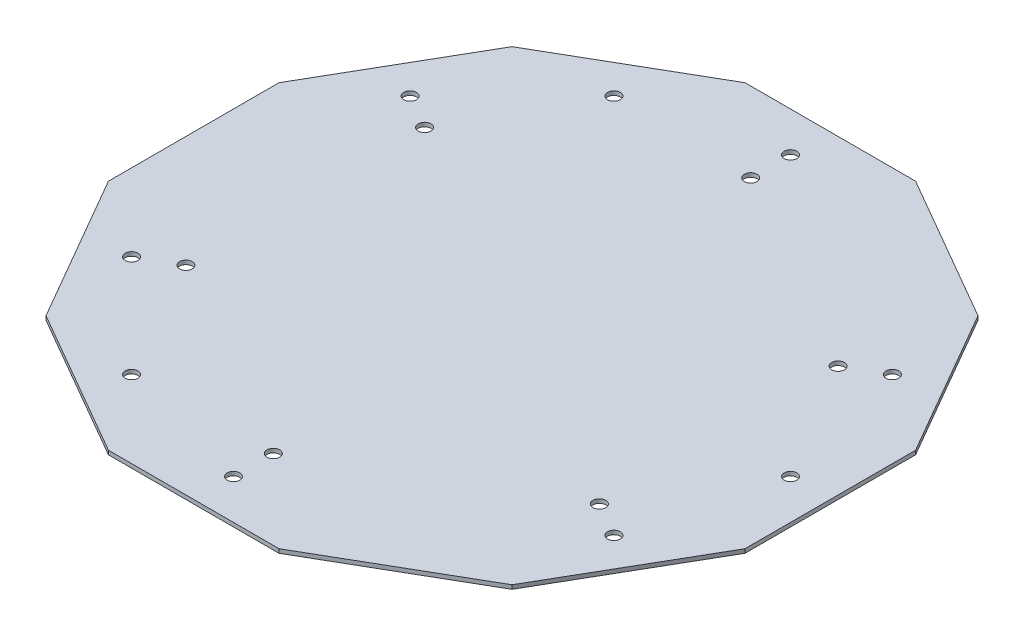
from build123d import *

# Parameters (mm, degrees)
EXTRUDE_2_DEPTH      = 1
SKETCH_9_R           = 1.6
CUT_EXTRUDE_5_DEPTH  = 1
SKETCH_10_R          = 1.6
CUT_EXTRUDE_6_DEPTH  = 1
SKETCH_11_R          = 1.6
CUT_EXTRUDE_7_DEPTH  = 1
SKETCH_12_R          = 1.6
CUT_EXTRUDE_8_DEPTH  = 1
SKETCH_16_R          = 1.6
CUT_EXTRUDE_9_DEPTH  = 1
SKETCH_17_R          = 1.6
CUT_EXTRUDE_10_DEPTH = 1
SKETCH_18_R          = 1.6
CUT_EXTRUDE_11_DEPTH = 1
SKETCH_19_R          = 1.6
CUT_EXTRUDE_12_DEPTH = 1
SKETCH_20_R          = 1.6
CUT_EXTRUDE_13_DEPTH = 1
SKETCH_21_R          = 1.6
CUT_EXTRUDE_14_DEPTH = 1
SKETCH_22_R          = 1.6
CUT_EXTRUDE_15_DEPTH = 1
SKETCH_23_R          = 1.6
CUT_EXTRUDE_16_DEPTH = 1
CUT_EXTRUDE_17_REACH = 3
SKETCH_24_R          = 1.6
CUT_EXTRUDE_18_REACH = 3
SKETCH_25_R          = 1.6
CUT_EXTRUDE_19_REACH = 3
SKETCH_26_R          = 1.6


with BuildPart() as part:
    # ｽｹｯﾁ8 → ﾎﾞｽ - 押し出し2 (new body)
    with BuildSketch(Plane(origin=(0, 0, 0), x_dir=(1, 0, 0), z_dir=(0, 1, 0))):
        Polygon((-80, -21.435935394), (-58.564064606, -58.564064606), (-21.435935394, -80), (21.435935394, -80), (58.564064606, -58.564064606), (80, -21.435935394), (80, 21.435935394), (58.564064606, 58.564064606), (21.435935394, 80), (-21.435935394, 80), (-58.564064606, 58.564064606), (-80, 21.435935394), align=None)
    extrude(amount=EXTRUDE_2_DEPTH)

    # ｽｹｯﾁ9 → ｶｯﾄ - 押し出し5 (cut)
    with BuildSketch(Plane(origin=(0, 1, 0), x_dir=(1, 0, 0), z_dir=(0, 1, 0))):
        with Locations((-60.621778265, 35)):
            Circle(SKETCH_9_R)
    extrude(amount=-CUT_EXTRUDE_5_DEPTH, mode=Mode.SUBTRACT)

    # ｽｹｯﾁ10 → ｶｯﾄ - 押し出し6 (cut)
    with BuildSketch(Plane(origin=(0, 1, 0), x_dir=(1, 0, 0), z_dir=(0, 1, 0))):
        with Locations((-51.961524227, 30)):
            Circle(SKETCH_10_R)
    extrude(amount=-CUT_EXTRUDE_6_DEPTH, mode=Mode.SUBTRACT)

    # ｽｹｯﾁ11 → ｶｯﾄ - 押し出し7 (cut)
    with BuildSketch(Plane(origin=(0, 1, 0), x_dir=(1, 0, 0), z_dir=(0, 1, 0))):
        with Locations((60.621778265, -35)):
            Circle(SKETCH_11_R)
    extrude(amount=-CUT_EXTRUDE_7_DEPTH, mode=Mode.SUBTRACT)

    # ｽｹｯﾁ12 → ｶｯﾄ - 押し出し8 (cut)
    with BuildSketch(Plane(origin=(0, 1, 0), x_dir=(1, 0, 0), z_dir=(0, 1, 0))):
        with Locations((51.961524227, -30)):
            Circle(SKETCH_12_R)
    extrude(amount=-CUT_EXTRUDE_8_DEPTH, mode=Mode.SUBTRACT)

    # ｽｹｯﾁ16 → ｶｯﾄ - 押し出し9 (cut)
    with BuildSketch(Plane(origin=(0, 1, 0), x_dir=(1, 0, 0), z_dir=(0, 1, 0))):
        with Locations((60.621778265, 35)):
            Circle(SKETCH_16_R)
    extrude(amount=-CUT_EXTRUDE_9_DEPTH, mode=Mode.SUBTRACT)

    # ｽｹｯﾁ17 → ｶｯﾄ - 押し出し10 (cut)
    with BuildSketch(Plane(origin=(0, 1, 0), x_dir=(1, 0, 0), z_dir=(0, 1, 0))):
        with Locations((51.961524227, 30)):
            Circle(SKETCH_17_R)
    extrude(amount=-CUT_EXTRUDE_10_DEPTH, mode=Mode.SUBTRACT)

    # ｽｹｯﾁ18 → ｶｯﾄ - 押し出し11 (cut)
    with BuildSketch(Plane(origin=(0, 1, 0), x_dir=(1, 0, 0), z_dir=(0, 1, 0))):
        with Locations((-60.621778265, -35)):
            Circle(SKETCH_18_R)
    extrude(amount=-CUT_EXTRUDE_11_DEPTH, mode=Mode.SUBTRACT)

    # ｽｹｯﾁ19 → ｶｯﾄ - 押し出し12 (cut)
    with BuildSketch(Plane(origin=(0, 1, 0), x_dir=(1, 0, 0), z_dir=(0, 1, 0))):
        with Locations((-51.961524227, -30)):
            Circle(SKETCH_19_R)
    extrude(amount=-CUT_EXTRUDE_12_DEPTH, mode=Mode.SUBTRACT)

    # ｽｹｯﾁ20 → ｶｯﾄ - 押し出し13 (cut)
    with BuildSketch(Plane(origin=(0, 1, 0), x_dir=(1, 0, 0), z_dir=(0, 1, 0))):
        with Locations((0, 70)):
            Circle(SKETCH_20_R)
    extrude(amount=-CUT_EXTRUDE_13_DEPTH, mode=Mode.SUBTRACT)

    # ｽｹｯﾁ21 → ｶｯﾄ - 押し出し14 (cut)
    with BuildSketch(Plane(origin=(0, 1, 0), x_dir=(1, 0, 0), z_dir=(0, 1, 0))):
        with Locations((0, 60)):
            Circle(SKETCH_21_R)
    extrude(amount=-CUT_EXTRUDE_14_DEPTH, mode=Mode.SUBTRACT)

    # ｽｹｯﾁ22 → ｶｯﾄ - 押し出し15 (cut)
    with BuildSketch(Plane(origin=(0, 1, 0), x_dir=(1, 0, 0), z_dir=(0, 1, 0))):
        with Locations((0, -70)):
            Circle(SKETCH_22_R)
    extrude(amount=-CUT_EXTRUDE_15_DEPTH, mode=Mode.SUBTRACT)

    # ｽｹｯﾁ23 → ｶｯﾄ - 押し出し16 (cut)
    with BuildSketch(Plane(origin=(0, 1, 0), x_dir=(1, 0, 0), z_dir=(0, 1, 0))):
        with Locations((0, -60)):
            Circle(SKETCH_23_R)
    extrude(amount=-CUT_EXTRUDE_16_DEPTH, mode=Mode.SUBTRACT)

    # ｽｹｯﾁ24 → ｶｯﾄ - 押し出し17 (cut, up to next)
    with BuildSketch(Plane(origin=(0, 1, 0), x_dir=(1, 0, 0), z_dir=(0, 1, 0)), mode=Mode.PRIVATE) as cut_extrude_17_sk1:
        with Locations((-35, 60.621778265)):
            Circle(SKETCH_24_R)
    cut_extrude_17_tool1 = extrude(cut_extrude_17_sk1.sketch, amount=-CUT_EXTRUDE_17_REACH, mode=Mode.PRIVATE) & part.part
    add(cut_extrude_17_tool1.solids().sort_by_distance((-35, 1, -60.621778))[0], mode=Mode.SUBTRACT)

    # ｽｹｯﾁ25 → ｶｯﾄ - 押し出し18 (cut, up to next)
    with BuildSketch(Plane(origin=(0, 1, 0), x_dir=(1, 0, 0), z_dir=(0, 1, 0)), mode=Mode.PRIVATE) as cut_extrude_18_sk1:
        with Locations((-35, -60.621778265)):
            Circle(SKETCH_25_R)
    cut_extrude_18_tool1 = extrude(cut_extrude_18_sk1.sketch, amount=-CUT_EXTRUDE_18_REACH, mode=Mode.PRIVATE) & part.part
    add(cut_extrude_18_tool1.solids().sort_by_distance((-35, 1, 60.621778))[0], mode=Mode.SUBTRACT)

    # ｽｹｯﾁ26 → ｶｯﾄ - 押し出し19 (cut, up to next)
    with BuildSketch(Plane(origin=(0, 1, 0), x_dir=(1, 0, 0), z_dir=(0, 1, 0)), mode=Mode.PRIVATE) as cut_extrude_19_sk1:
        with Locations((70, 0)):
            Circle(SKETCH_26_R)
    cut_extrude_19_tool1 = extrude(cut_extrude_19_sk1.sketch, amount=-CUT_EXTRUDE_19_REACH, mode=Mode.PRIVATE) & part.part
    add(cut_extrude_19_tool1.solids().sort_by_distance((70, 1, 0))[0], mode=Mode.SUBTRACT)


solid = part.part
